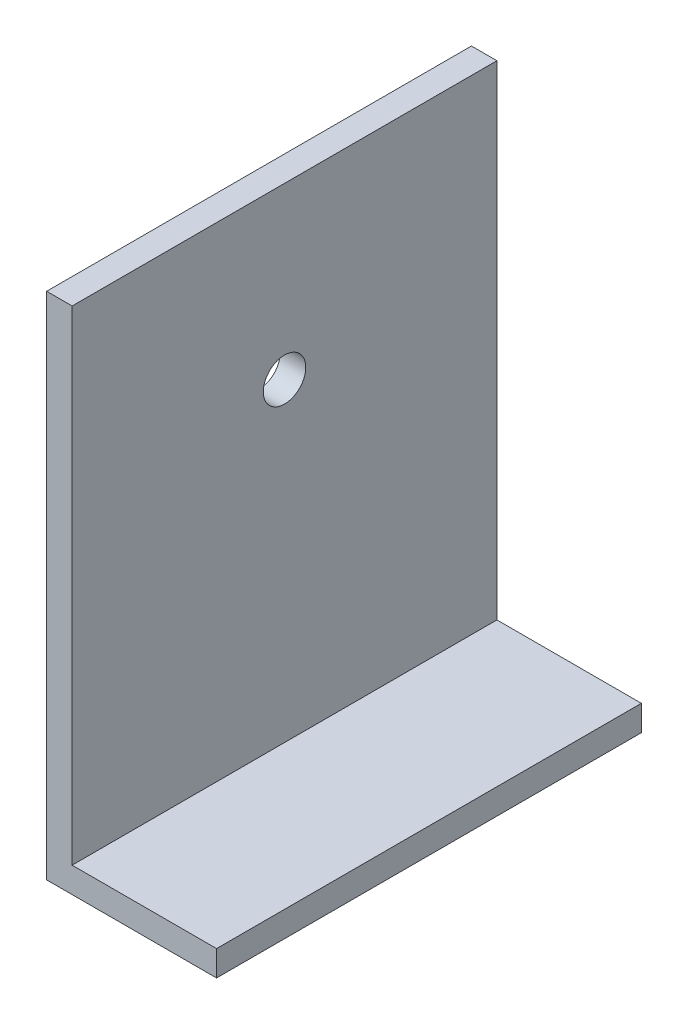
from build123d import *

# Parameters (mm, degrees)
BOSS_EXTRUDE1_DEPTH = 50
SKETCH2_R           = 2.5
CUT_EXTRUDE1_DEPTH  = 21


with BuildPart() as part:
    # Sketch1 → Boss-Extrude1 (new body)
    with BuildSketch(Plane.XY):
        Polygon((0, 0), (20, 0), (20, 3), (3, 3), (3, 60), (0, 60), align=None)
    extrude(amount=BOSS_EXTRUDE1_DEPTH)

    # Sketch2 → Cut-Extrude1 (cut, through all)
    with BuildSketch(Plane.ZY):
        with Locations((25, 40)):
            Circle(SKETCH2_R)
    extrude(amount=-CUT_EXTRUDE1_DEPTH, mode=Mode.SUBTRACT)


solid = part.part
